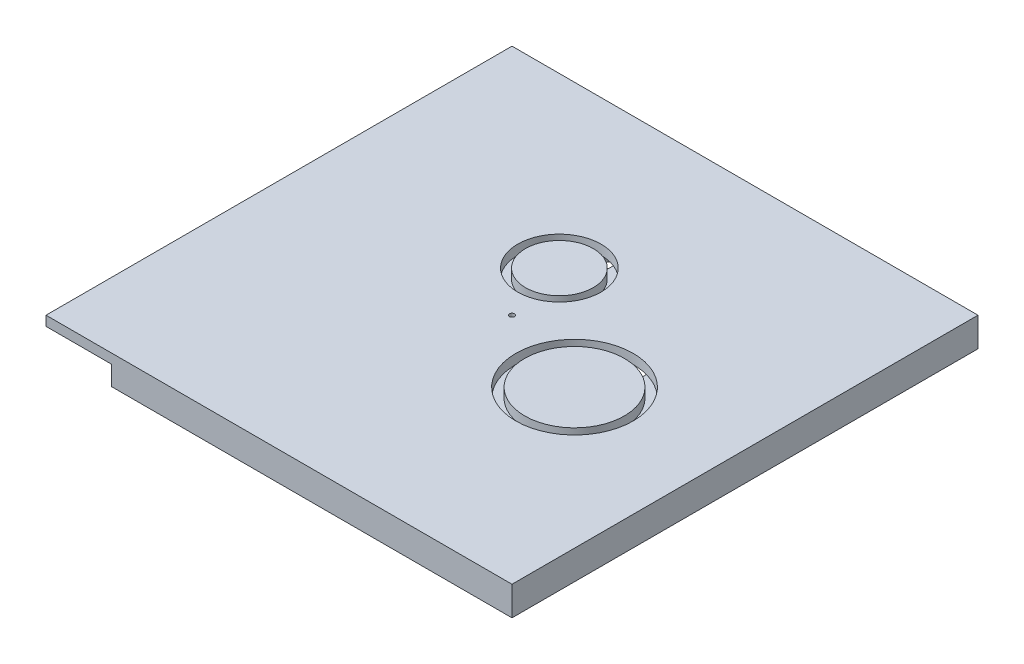
from build123d import *
from build123d.topology import SkipClean

# Parameters (mm, degrees)
SKETCH1_R             = 22.146000031
BOSS_EXTRUDE1_DEPTH   = 19.05
SKETCH1_R_2           = 32.595999959
BOSS_EXTRUDE1_2_DEPTH = 19.05
SKETCH1_W             = 304.8
SKETCH1_H             = 304.8
SKETCH1_R_3           = 27.229000025
SKETCH1_R_4           = 38.354
SKETCH1_R_5           = 1.651
BOSS_EXTRUDE1_3_DEPTH = 19.05
SKETCH1_4_R           = 27.229000025
SKETCH1_4_R_2         = 22.146000031
SKETCH1_4_R_3         = 38.354
SKETCH1_4_R_4         = 32.595999959
BOSS_EXTRUDE2_DEPTH   = 12.7
SKETCH1_5_R           = 1.651
CUT_EXTRUDE1_DEPTH    = 12.7
SKETCH5_R             = 2.032
SKETCH5_R_2           = 2.38125
CUT_EXTRUDE2_DEPTH    = 13.7


with BuildPart() as part:
    # Sketch1 → Boss-Extrude1 (new body)
    with BuildSketch(Plane(origin=(0, 0, 0), x_dir=(1, 0, 0), z_dir=(0, 1, 0))):
        with Locations(Location((-11.176, 42.164, 0), (0, 0, 270))):  # turned: the seam where the file's is
            Circle(SKETCH1_R)
    extrude(amount=BOSS_EXTRUDE1_DEPTH)



with BuildPart() as body_2:
    # Sketch1 → Boss-Extrude1 2 (new body)
    with BuildSketch(Plane(origin=(0, 0, 0), x_dir=(1, 0, 0), z_dir=(0, 1, 0))):
        with Locations(Location((61.214, -20.32, 0), (0, 0, 270))):  # turned: the seam where the file's is
            Circle(SKETCH1_R_2)
    extrude(amount=BOSS_EXTRUDE1_2_DEPTH)


with BuildPart() as body_3:
    # Sketch1 → Boss-Extrude1 3 (new body)
    with BuildSketch(Plane(origin=(0, 0, 0), x_dir=(1, 0, 0), z_dir=(0, 1, 0))):
        Rectangle(SKETCH1_W, SKETCH1_H)
        with Locations(Location((-11.176, 42.164, 0), (0, 0, 270))):  # turned: the seam where the file's is
            Circle(SKETCH1_R_3, mode=Mode.SUBTRACT)
        with Locations(Location((61.214, -20.32, 0), (0, 0, 270))):  # turned: the seam where the file's is
            Circle(SKETCH1_R_4, mode=Mode.SUBTRACT)
        with Locations(Location((0, 0, 0), (0, 0, 270))):  # turned: the seam where the file's is
            Circle(SKETCH1_R_5, mode=Mode.SUBTRACT)
    extrude(amount=BOSS_EXTRUDE1_3_DEPTH)


with BuildPart() as part_1:
    with SkipClean():  # keep this step's faces unmerged: merging them makes the solid invalid here
        add(part.part)

        add(body_2.part)  # Boss-Extrude2 merges body 2

        add(body_3.part)  # Boss-Extrude2 merges body 3
        # Sketch1_4 → Boss-Extrude2 (add)
        with BuildSketch(Plane(origin=(0, 0, 0), x_dir=(1, 0, 0), z_dir=(0, 1, 0))):
            with Locations(Location((-11.176, 42.164, 0), (0, 0, 270))):  # turned: the seam where the file's is
                Circle(SKETCH1_4_R)
            with Locations(Location((-11.176, 42.164, 0), (0, 0, 270))):  # turned: the seam where the file's is
                Circle(SKETCH1_4_R_2, mode=Mode.SUBTRACT)
            with Locations(Location((61.214, -20.32, 0), (0, 0, 270))):  # turned: the seam where the file's is
                Circle(SKETCH1_4_R_3)
            with Locations(Location((61.214, -20.32, 0), (0, 0, 270))):  # turned: the seam where the file's is
                Circle(SKETCH1_4_R_4, mode=Mode.SUBTRACT)
            with BuildLine():
                ThreePointArc((99.568, -20.32), (91.665349034, 2.998333088), (71.214, 16.707413034))
                Line((71.214, 16.707413034), (71.214, 10.704171437))
                ThreePointArc((71.214, 10.704171437), (87.562237255, -1.129648079), (93.809999959, -20.32))
                ThreePointArc((93.809999959, -20.32), (42.023648079, -46.668237255), (51.214, 10.704171437))
                Line((51.214, 10.704171437), (51.214, 16.707413034))
                ThreePointArc((51.214, 16.707413034), (37.895666912, -50.771349034), (99.568, -20.32))
            make_face()
            with BuildLine():
                Line((71.214, 10.704171437), (71.214, 16.707413034))
                ThreePointArc((71.214, 16.707413034), (61.214, 18.034), (51.214, 16.707413034))
                Line((51.214, 16.707413034), (51.214, 10.704171437))
                ThreePointArc((51.214, 10.704171437), (61.214, 12.275999959), (71.214, 10.704171437))
            make_face()
            with BuildLine():
                ThreePointArc((-1.176, 67.490240194), (-11.176, 69.393000025), (-21.176, 67.490240194))
                Line((-21.176, 67.490240194), (-21.176, 61.923689202))
                ThreePointArc((-21.176, 61.923689202), (-11.176, 64.310000031), (-1.176, 61.923689202))
                Line((-1.176, 61.923689202), (-1.176, 67.490240194))
            make_face()
            with BuildLine():
                Line((-21.176, 61.923689202), (-21.176, 67.490240194))
                ThreePointArc((-21.176, 67.490240194), (-26.491489579, 19.650576864), (16.053000025, 42.164))
                ThreePointArc((16.053000025, 42.164), (11.337423136, 57.479489579), (-1.176, 67.490240194))
                Line((-1.176, 67.490240194), (-1.176, 61.923689202))
                ThreePointArc((-1.176, 61.923689202), (7.690707684, 53.761096987), (10.970000031, 42.164))
                ThreePointArc((10.970000031, 42.164), (-22.773096987, 23.297292316), (-21.176, 61.923689202))
            make_face()
        extrude(amount=BOSS_EXTRUDE2_DEPTH)

    # Sketch1_5 → Cut-Extrude1 (cut)
    with SkipClean():  # keep this step's faces unmerged: merging them makes the solid invalid here
        with BuildSketch(Plane(origin=(0, 0, 0), x_dir=(1, 0, 0), z_dir=(0, 1, 0))):
            Polygon((-124.40847096, -109.680850921), (-152.4, -109.680850921), (-152.4, -152.4), (-109.680850921, -152.4), (-109.680850921, -124.40847096), align=None)
            with BuildLine():
                ThreePointArc((71.214, 16.707413034), (68.771077011, 30.302427293), (61.747960937, 42.196464709))
                Line((61.747960937, 42.196464709), (25.136544704, 84.689638699))
                ThreePointArc((25.136544704, 84.689638699), (-3.999588367, 92.191814566), (-21.176, 67.490240194))
                Line((-21.176, 67.490240194), (-21.176, 61.923689202))
                ThreePointArc((-21.176, 61.923689202), (-11.176, 64.310000031), (-1.176, 61.923689202))
                Line((-1.176, 61.923689202), (-1.176, 67.490240194))
                ThreePointArc((-1.176, 67.490240194), (2.963287054, 73.442991513), (9.984708116, 71.635066779))
                Line((9.984708116, 71.635066779), (31.14615486, 47.073956315))
                ThreePointArc((31.14615486, 47.073956315), (32.128503793, 44.270491708), (30.940983624, 41.547585342))
                Line((30.940983624, 41.547585342), (-27.66770876, -17.061107042))
                Line((-27.66770876, -17.061107042), (-118.661107042, -17.061107042))
                Line((-118.661107042, -17.061107042), (-118.661107042, -109.680850921))
                Line((-118.661107042, -109.680850921), (-109.680850921, -118.661107042))
                Line((-109.680850921, -118.661107042), (-17.061107042, -118.661107042))
                Line((-17.061107042, -118.661107042), (-17.061107042, -27.66770876))
                Line((-17.061107042, -27.66770876), (40.331599468, 29.72499775))
                ThreePointArc((40.331599468, 29.72499775), (43.35605702, 30.912517919), (46.284134621, 29.504004806))
                Line((46.284134621, 29.504004806), (46.596124349, 29.141892789))
                ThreePointArc((46.596124349, 29.141892789), (50.022253958, 23.339551873), (51.214, 16.707413034))
                Line((51.214, 16.707413034), (51.214, 10.704171437))
                ThreePointArc((51.214, 10.704171437), (61.214, 12.275999959), (71.214, 10.704171437))
                Line((71.214, 10.704171437), (71.214, 16.707413034))
            make_face()
            with Locations(Location((0, 0, 0), (0, 0, 270))):  # turned: the seam where the file's is
                Circle(SKETCH1_5_R, mode=Mode.SUBTRACT)
        extrude(amount=CUT_EXTRUDE1_DEPTH, mode=Mode.SUBTRACT)

    # Sketch5 → Cut-Extrude2 (cut, through all)
    with SkipClean():  # keep this step's faces unmerged: merging them makes the solid invalid here
        with BuildSketch(Plane(origin=(0, 12.7, 0), x_dir=(1, 0, 0), z_dir=(0, 1, 0))):
            with Locations(Location((-11.176, 17.476499972, 0), (0, 0, 270))):  # turned: the seam where the file's is
                Circle(SKETCH5_R)
            with Locations(Location((13.511500028, 42.164, 0), (0, 0, 270))):  # turned: the seam where the file's is
                Circle(SKETCH5_R)
            with Locations(Location((-35.863500028, 42.164, 0), (0, 0, 270))):  # turned: the seam where the file's is
                Circle(SKETCH5_R)
            with Locations(Location((25.739000021, -20.32, 0), (0, 0, 270))):  # turned: the seam where the file's is
                Circle(SKETCH5_R_2)
            with Locations(Location((96.68899998, -20.32, 0), (0, 0, 270))):  # turned: the seam where the file's is
                Circle(SKETCH5_R_2)
            with Locations(Location((61.214, -55.794999979, 0), (0, 0, 270))):  # turned: the seam where the file's is
                Circle(SKETCH5_R_2)
        extrude(amount=-CUT_EXTRUDE2_DEPTH, mode=Mode.SUBTRACT)


solid = part_1.part
